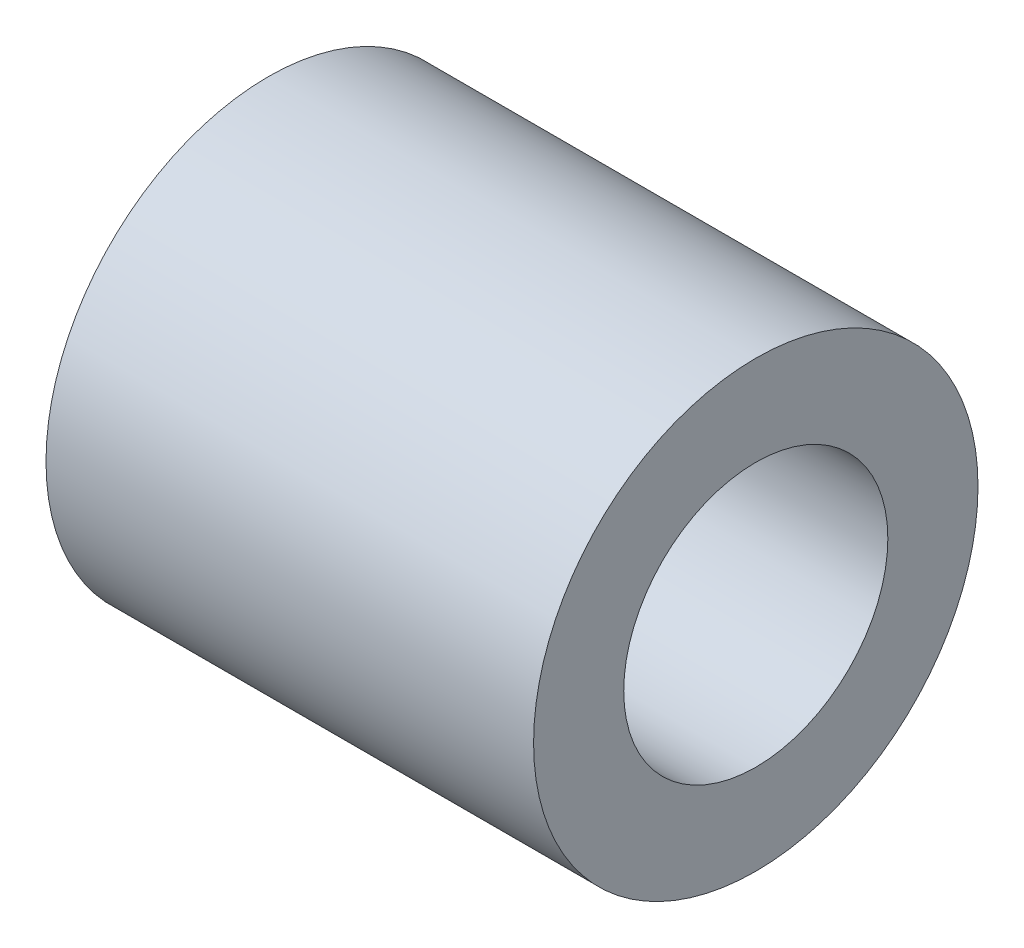
from build123d import *

# Parameters (mm, degrees)
SKETCH1_R           = 5.55625
SKETCH1_R_2         = 3.302
BOSS_EXTRUDE1_DEPTH = 12.192


with BuildPart() as part:
    # Sketch1 → Boss-Extrude1 (new body)
    with BuildSketch(Plane(origin=(0, 0, 0), x_dir=(0, 0, -1), z_dir=(1, 0, 0))):
        Circle(SKETCH1_R)
        Circle(SKETCH1_R_2, mode=Mode.SUBTRACT)
    extrude(amount=BOSS_EXTRUDE1_DEPTH)


solid = part.part
